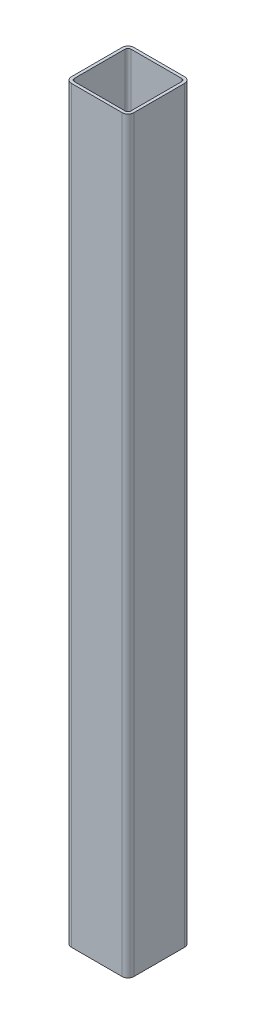
from build123d import *

# Parameters (mm, degrees)
BOSS_EXTRUDE1_DEPTH = 609.6


with BuildPart() as part:
    # Sketch1 → Boss-Extrude1 (new body, symmetric)
    with BuildSketch(Plane(origin=(0, 0, 0), x_dir=(1, 0, 0), z_dir=(0, 1, 0))):
        with BuildLine():
            Line((-41.275, -50.8), (41.275, -50.8))
            ThreePointArc((41.275, -50.8), (48.010192091, -48.010192091), (50.8, -41.275))
            Line((50.8, -41.275), (50.8, 41.275))
            ThreePointArc((50.8, 41.275), (48.010192091, 48.010192091), (41.275, 50.8))
            Line((41.275, 50.8), (-41.275, 50.8))
            ThreePointArc((-41.275, 50.8), (-48.010192091, 48.010192091), (-50.8, 41.275))
            Line((-50.8, 41.275), (-50.8, -41.275))
            ThreePointArc((-50.8, -41.275), (-48.010192091, -48.010192091), (-41.275, -50.8))
        make_face()
        with BuildLine():
            Line((-41.275, -46.0375), (41.275, -46.0375))
            ThreePointArc((41.275, -46.0375), (44.642596045, -44.642596045), (46.0375, -41.275))
            Line((46.0375, -41.275), (46.0375, 41.275))
            ThreePointArc((46.0375, 41.275), (44.642596045, 44.642596045), (41.275, 46.0375))
            Line((41.275, 46.0375), (-41.275, 46.0375))
            ThreePointArc((-41.275, 46.0375), (-44.642596045, 44.642596045), (-46.0375, 41.275))
            Line((-46.0375, 41.275), (-46.0375, -41.275))
            ThreePointArc((-46.0375, -41.275), (-44.642596045, -44.642596045), (-41.275, -46.0375))
        make_face(mode=Mode.SUBTRACT)
    extrude(amount=BOSS_EXTRUDE1_DEPTH, both=True)


solid = part.part
